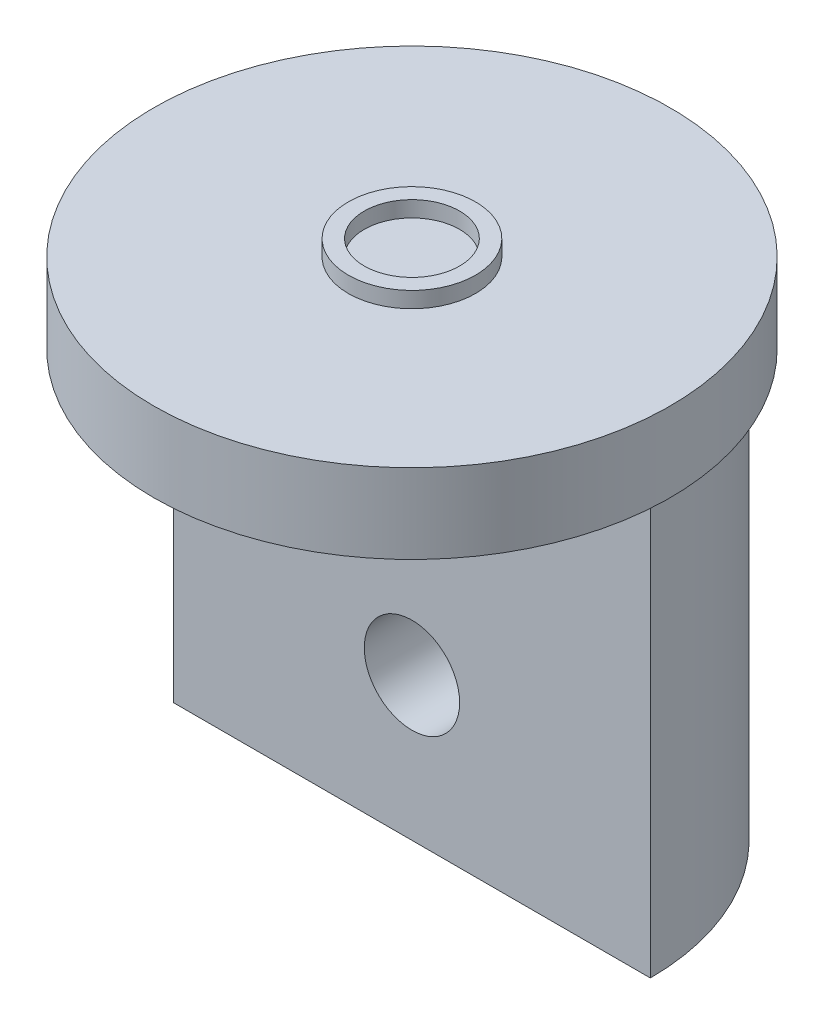
from build123d import *

# Parameters (mm, degrees)
SKETCH1_R           = 32.5
SKETCH1_R_2         = 30
BOSS_EXTRUDE3_DEPTH = 10
BOSS_EXTRUDE4_DEPTH = 63.5872
BOSS_EXTRUDE5_DEPTH = 10
SKETCH2_R           = 6
CUT_EXTRUDE1_DEPTH  = 45
SKETCH3_R           = 8
SKETCH3_R_2         = 6
BOSS_EXTRUDE6_DEPTH = 2


with BuildPart() as part:
    # Sketch1 → Boss-Extrude3 (new body)
    with BuildSketch(Plane(origin=(0, 0, 0), x_dir=(1, 0, 0), z_dir=(0, 1, 0))):
        Circle(SKETCH1_R)
        Circle(SKETCH1_R_2, mode=Mode.SUBTRACT)
    extrude(amount=-BOSS_EXTRUDE3_DEPTH)

    # Sketch1_3 → Boss-Extrude4 (add)
    with BuildSketch(Plane(origin=(0, 0, 0), x_dir=(1, 0, 0), z_dir=(0, 1, 0))):
        with BuildLine():
            Line((-30, 0), (30, 0))
            ThreePointArc((30, 0), (0, 30), (-30, 0))
        make_face()
    extrude(amount=-BOSS_EXTRUDE4_DEPTH)

    # Sketch1_4 → Boss-Extrude5 (add)
    with BuildSketch(Plane(origin=(0, 0, 0), x_dir=(1, 0, 0), z_dir=(0, 1, 0))):
        with BuildLine():
            ThreePointArc((-30, 0), (0, -30), (30, 0))
            Line((30, 0), (-30, 0))
        make_face()
    extrude(amount=-BOSS_EXTRUDE5_DEPTH)

    # Sketch2 → Cut-Extrude1 (cut)
    with BuildSketch(Plane.XY):
        with Locations((0, -45.5872)):
            Circle(SKETCH2_R)
    extrude(amount=-CUT_EXTRUDE1_DEPTH, mode=Mode.SUBTRACT)

    # Sketch3 → Boss-Extrude6 (add)
    with BuildSketch(Plane(origin=(0, 0, 0), x_dir=(1, 0, 0), z_dir=(0, 1, 0))):
        Circle(SKETCH3_R)
        Circle(SKETCH3_R_2, mode=Mode.SUBTRACT)
    extrude(amount=BOSS_EXTRUDE6_DEPTH)


solid = part.part
